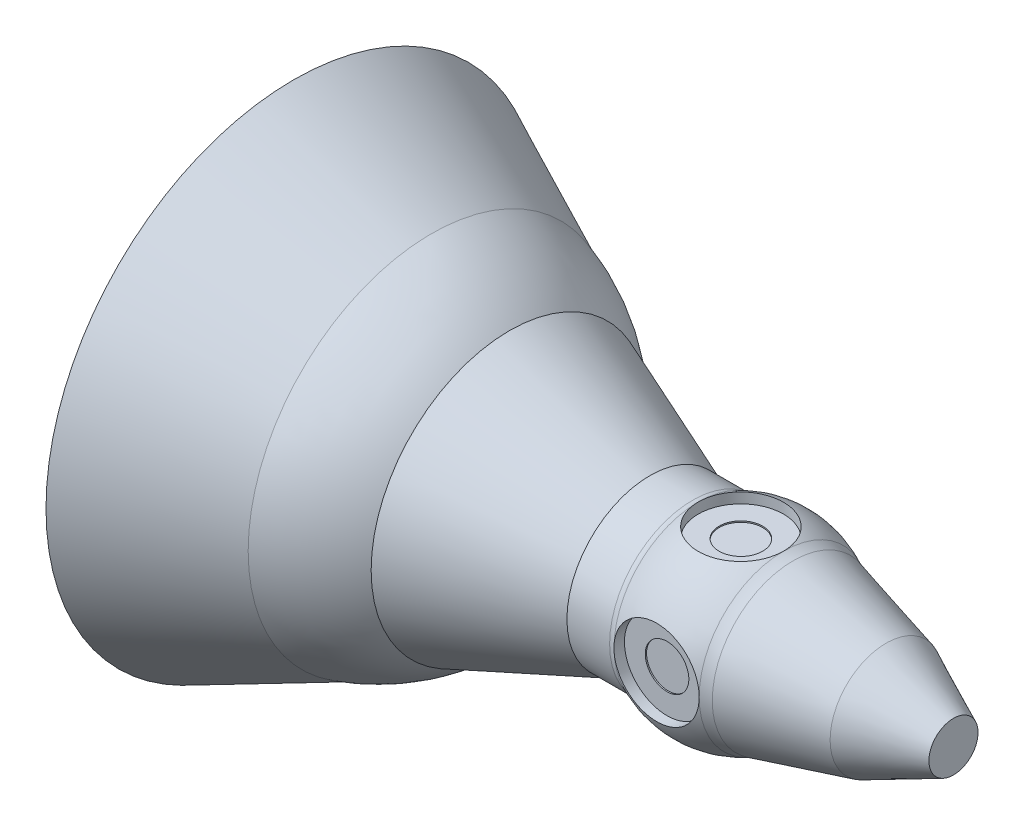
from build123d import *

# Parameters (mm, degrees)
PADR_OCIRCULAR1_COUNT = 4


with BuildPart() as part:
    # Esboço1 → Revolução1 (revolve)
    with BuildSketch(Plane.XY):
        with BuildLine():
            Line((3317.399667889, 0), (3317.399667889, 383.5))
            Line((3317.399667889, 383.5), (2265.399667889, 873))
            Line((2265.399667889, 873), (813.399667889, 1260))
            ThreePointArc((813.399667889, 1260), (737.813781205, 1284.220696189), (665, 1315.812176946))
            ThreePointArc((665, 1315.812176946), (0, 1471.161405015), (-665, 1315.812176946))
            ThreePointArc((-665, 1315.812176946), (-708.110967822, 1300.356342101), (-753.607594937, 1295.112746158))
            Line((-753.607594937, 1295.112746158), (-1420, 1295.112746158))
            Line((-1420, 1295.112746158), (-3610, 2160))
            ThreePointArc((-3610, 2160), (-4176.936739119, 2584.120878591), (-4829, 2860))
            Line((-4829, 2860), (-6980, 3864))
            Line((-6980, 3864), (-6980, 0))
            Line((-6980, 0), (3317.399667889, 0))
        make_face()
    revolve(axis=Axis((-6980, 0, 0), (1, 0, 0)))

    # Esboço2 → Corte-Revolução7 (revolve, cut)
    with BuildSketch(Plane(origin=(0, 0, 0), x_dir=(0, 0, -1), z_dir=(1, 0, 0))):
        Polygon((665, 1312.284603127), (665, 1152.284603127), (340, 1152.284603127), (340, 1132.284603127), (0, 1132.284603127), (0, 1471.161405015), (0, 1794.497439154), (665, 1794.497439154), align=None)
    corte_revolu_o7 = revolve(axis=Axis((0, 0, 0), (0, 1, 0)), mode=Mode.SUBTRACT)

    # PadrãoCircular1: Corte-Revolução7 ×4 about axis
    padr_ocircular1_axis = Axis((0, 0, 0), (1, 0, 0))
    for i in range(1, PADR_OCIRCULAR1_COUNT):
        add(corte_revolu_o7.rotate(padr_ocircular1_axis, i * 360 / PADR_OCIRCULAR1_COUNT), mode=Mode.SUBTRACT)


solid = part.part
